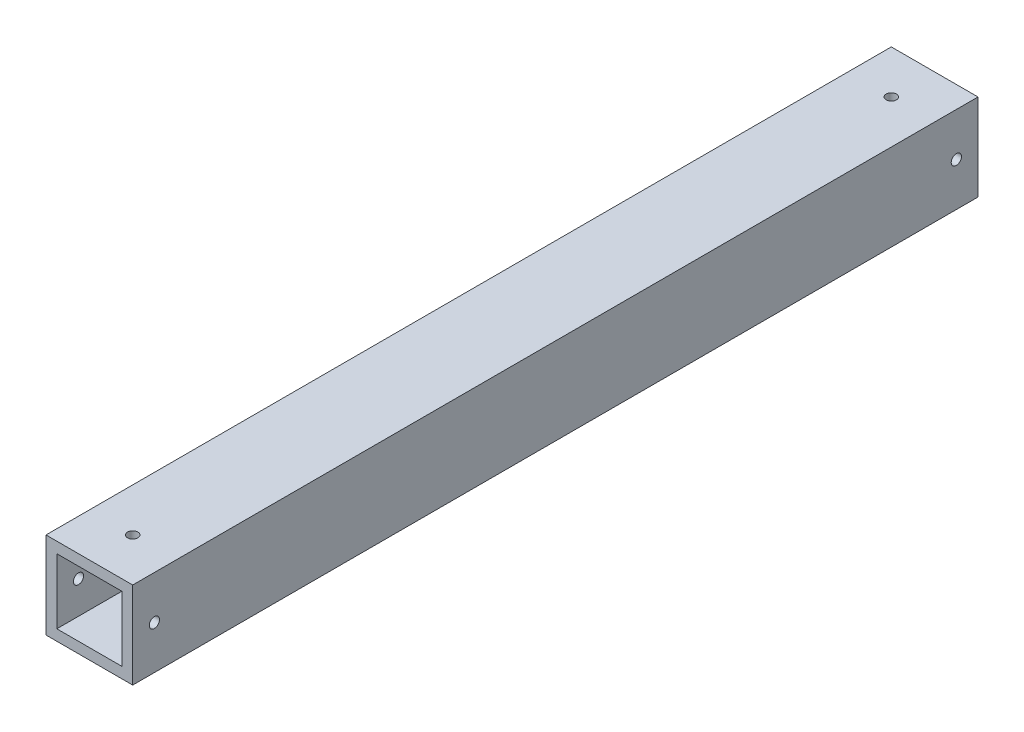
from build123d import *

# Parameters (mm, degrees)
SKETCH1_W           = 25.4
SKETCH1_H           = 25.4
SKETCH1_W_2         = 19.05
SKETCH1_H_2         = 19.05
BOSS_EXTRUDE1_DEPTH = 247.65
SKETCH2_R           = 1.5
CUT_EXTRUDE1_DEPTH  = 254
SKETCH3_R           = 1.5
CUT_EXTRUDE2_DEPTH  = 254


with BuildPart() as part:
    # Sketch1 → Boss-Extrude1 (new body)
    with BuildSketch(Plane.XY):
        Rectangle(SKETCH1_W, SKETCH1_H)
        Rectangle(SKETCH1_W_2, SKETCH1_H_2, mode=Mode.SUBTRACT)
    extrude(amount=BOSS_EXTRUDE1_DEPTH)

    # Sketch2 → Cut-Extrude1 (cut)
    with BuildSketch(Plane(origin=(12.7, 0, 0), x_dir=(0, 0, -1), z_dir=(1, 0, 0))):
        with Locations((-241.3, 0)):
            Circle(SKETCH2_R)
        with Locations((-6.35, 0)):
            Circle(SKETCH2_R)
    extrude(amount=-CUT_EXTRUDE1_DEPTH, mode=Mode.SUBTRACT)

    # Sketch3 → Cut-Extrude2 (cut)
    with BuildSketch(Plane(origin=(0, 12.7, 0), x_dir=(1, 0, 0), z_dir=(0, 1, 0))):
        with Locations((0, -12.7)):
            Circle(SKETCH3_R)
        with Locations((0, -234.95)):
            Circle(SKETCH3_R)
    extrude(amount=-CUT_EXTRUDE2_DEPTH, mode=Mode.SUBTRACT)


solid = part.part
